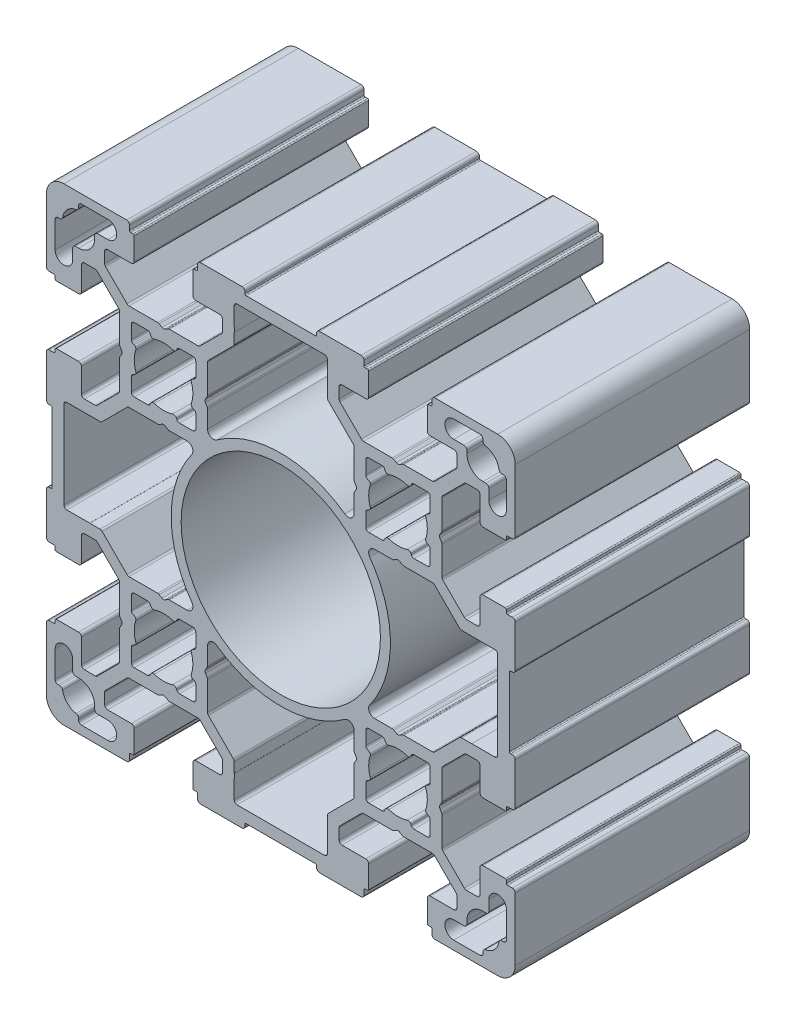
from build123d import *

# Parameters (mm, degrees)
SKETCH_1_R      = 17
EXTRUDE_2_DEPTH = 40


with BuildPart() as part:
    # Эскиз1 → Бобышка-Вытянуть2 (new body)
    with BuildSketch(Plane.XY):
        with BuildLine():
            Line((19.10095497, 46.510086301), (19.60095497, 46.798761436))
            ThreePointArc((19.60095497, 46.798761436), (19.721545448, 46.848711647), (19.85095497, 46.865748734))
            Line((19.85095497, 46.865748734), (24.729634627, 46.865748734))
            ThreePointArc((24.729634627, 46.865748734), (24.920976343, 46.903808968), (25.083188017, 47.012195343))
            Line((25.083188017, 47.012195343), (28.754508361, 50.683515687))
            ThreePointArc((28.754508361, 50.683515687), (28.862894737, 50.845727361), (28.90095497, 51.037069077))
            Line((28.90095497, 51.037069077), (28.90095497, 52.865748734))
            ThreePointArc((28.90095497, 52.865748734), (28.754508361, 53.219302125), (28.40095497, 53.365748734))
            Line((28.40095497, 53.365748734), (24.35095497, 53.365748734))
            ThreePointArc((24.35095497, 53.365748734), (23.99740158, 53.512195343), (23.85095497, 53.865748734))
            Line((23.85095497, 53.865748734), (23.85095497, 57.665748734))
            ThreePointArc((23.85095497, 57.665748734), (23.909533614, 57.80717009), (24.05095497, 57.865748734))
            Line((24.05095497, 57.865748734), (24.45095497, 57.865748734))
            ThreePointArc((24.45095497, 57.865748734), (24.592376327, 57.924327378), (24.65095497, 58.065748734))
            Line((24.65095497, 58.065748734), (24.65095497, 58.865748734))
            ThreePointArc((24.65095497, 58.865748734), (24.79740158, 59.219302125), (25.15095497, 59.365748734))
            Line((25.15095497, 59.365748734), (32.24095497, 59.365748734))
            ThreePointArc((32.24095497, 59.365748734), (32.594508361, 59.219302125), (32.74095497, 58.865748734))
            Line((32.74095497, 58.865748734), (32.74095497, 58.565748734))
            ThreePointArc((32.74095497, 58.565748734), (32.799533614, 58.424327378), (32.94095497, 58.365748734))
            Line((32.94095497, 58.365748734), (44.76095497, 58.365748734))
            ThreePointArc((44.76095497, 58.365748734), (44.902376327, 58.424327378), (44.96095497, 58.565748734))
            Line((44.96095497, 58.565748734), (44.96095497, 58.865748734))
            ThreePointArc((44.96095497, 58.865748734), (45.10740158, 59.219302125), (45.46095497, 59.365748734))
            Line((45.46095497, 59.365748734), (52.55095497, 59.365748734))
            ThreePointArc((52.55095497, 59.365748734), (52.904508361, 59.219302125), (53.05095497, 58.865748734))
            Line((53.05095497, 58.865748734), (53.05095497, 58.065748734))
            ThreePointArc((53.05095497, 58.065748734), (53.109533614, 57.924327378), (53.25095497, 57.865748734))
            Line((53.25095497, 57.865748734), (53.65095497, 57.865748734))
            ThreePointArc((53.65095497, 57.865748734), (53.792376327, 57.80717009), (53.85095497, 57.665748734))
            Line((53.85095497, 57.665748734), (53.85095497, 53.865748734))
            ThreePointArc((53.85095497, 53.865748734), (53.704508361, 53.512195343), (53.35095497, 53.365748734))
            Line((53.35095497, 53.365748734), (49.30095497, 53.365748734))
            ThreePointArc((49.30095497, 53.365748734), (48.94740158, 53.219302125), (48.80095497, 52.865748734))
            Line((48.80095497, 52.865748734), (48.80095497, 51.037069077))
            ThreePointArc((48.80095497, 51.037069077), (48.839015204, 50.845727361), (48.94740158, 50.683515687))
            Line((48.94740158, 50.683515687), (52.618721923, 47.012195343))
            ThreePointArc((52.618721923, 47.012195343), (52.780933598, 46.903808968), (52.972275314, 46.865748734))
            Line((52.972275314, 46.865748734), (57.85095497, 46.865748734))
            ThreePointArc((57.85095497, 46.865748734), (57.980364493, 46.848711647), (58.10095497, 46.798761436))
            Line((58.10095497, 46.798761436), (58.60095497, 46.510086301))
            ThreePointArc((58.60095497, 46.510086301), (58.85095497, 46.443099003), (59.10095497, 46.510086301))
            Line((59.10095497, 46.510086301), (59.60095497, 46.798761436))
            ThreePointArc((59.60095497, 46.798761436), (59.721545448, 46.848711647), (59.85095497, 46.865748734))
            Line((59.85095497, 46.865748734), (64.729634627, 46.865748734))
            ThreePointArc((64.729634627, 46.865748734), (64.920976343, 46.903808968), (65.083188017, 47.012195343))
            Line((65.083188017, 47.012195343), (68.754508361, 50.683515687))
            ThreePointArc((68.754508361, 50.683515687), (68.862894737, 50.845727361), (68.90095497, 51.037069077))
            Line((68.90095497, 51.037069077), (68.90095497, 52.865748734))
            ThreePointArc((68.90095497, 52.865748734), (68.754508361, 53.219302125), (68.40095497, 53.365748734))
            Line((68.40095497, 53.365748734), (64.35095497, 53.365748734))
            ThreePointArc((64.35095497, 53.365748734), (63.99740158, 53.512195343), (63.85095497, 53.865748734))
            Line((63.85095497, 53.865748734), (63.85095497, 57.665748734))
            ThreePointArc((63.85095497, 57.665748734), (63.909533614, 57.80717009), (64.05095497, 57.865748734))
            Line((64.05095497, 57.865748734), (64.45095497, 57.865748734))
            ThreePointArc((64.45095497, 57.865748734), (64.592376327, 57.924327378), (64.65095497, 58.065748734))
            Line((64.65095497, 58.065748734), (64.65095497, 58.865748734))
            ThreePointArc((64.65095497, 58.865748734), (64.79740158, 59.219302125), (65.15095497, 59.365748734))
            Line((65.15095497, 59.365748734), (75.85095497, 59.365748734))
            ThreePointArc((75.85095497, 59.365748734), (77.972275314, 58.487069077), (78.85095497, 56.365748734))
            Line((78.85095497, 56.365748734), (78.85095497, 45.665748734))
            ThreePointArc((78.85095497, 45.665748734), (78.704508361, 45.312195343), (78.35095497, 45.165748734))
            Line((78.35095497, 45.165748734), (77.55095497, 45.165748734))
            ThreePointArc((77.55095497, 45.165748734), (77.409533614, 45.10717009), (77.35095497, 44.965748734))
            Line((77.35095497, 44.965748734), (77.35095497, 44.565748734))
            ThreePointArc((77.35095497, 44.565748734), (77.292376327, 44.424327378), (77.15095497, 44.365748734))
            Line((77.15095497, 44.365748734), (73.35095497, 44.365748734))
            ThreePointArc((73.35095497, 44.365748734), (72.99740158, 44.512195343), (72.85095497, 44.865748734))
            Line((72.85095497, 44.865748734), (72.85095497, 48.915748734))
            ThreePointArc((72.85095497, 48.915748734), (72.704508361, 49.269302125), (72.35095497, 49.415748734))
            Line((72.35095497, 49.415748734), (70.522275314, 49.415748734))
            ThreePointArc((70.522275314, 49.415748734), (70.330933598, 49.3776885), (70.168721923, 49.269302125))
            Line((70.168721923, 49.269302125), (66.49740158, 45.597981781))
            ThreePointArc((66.49740158, 45.597981781), (66.389015204, 45.435770107), (66.35095497, 45.24442839))
            Line((66.35095497, 45.24442839), (66.35095497, 40.365748734))
            ThreePointArc((66.35095497, 40.365748734), (66.333917884, 40.236339211), (66.283967672, 40.115748734))
            Line((66.283967672, 40.115748734), (65.995292538, 39.615748734))
            ThreePointArc((65.995292538, 39.615748734), (65.92830524, 39.365748734), (65.995292538, 39.115748734))
            Line((65.995292538, 39.115748734), (66.283967672, 38.615748734))
            ThreePointArc((66.283967672, 38.615748734), (66.333917884, 38.495158256), (66.35095497, 38.365748734))
            Line((66.35095497, 38.365748734), (66.35095497, 33.487069077))
            ThreePointArc((66.35095497, 33.487069077), (66.389015204, 33.295727361), (66.49740158, 33.133515687))
            Line((66.49740158, 33.133515687), (70.168721923, 29.462195343))
            ThreePointArc((70.168721923, 29.462195343), (70.330933598, 29.353808968), (70.522275314, 29.315748734))
            Line((70.522275314, 29.315748734), (72.35095497, 29.315748734))
            ThreePointArc((72.35095497, 29.315748734), (72.704508361, 29.462195343), (72.85095497, 29.815748734))
            Line((72.85095497, 29.815748734), (72.85095497, 33.865748734))
            ThreePointArc((72.85095497, 33.865748734), (72.99740158, 34.219302125), (73.35095497, 34.365748734))
            Line((73.35095497, 34.365748734), (77.15095497, 34.365748734))
            ThreePointArc((77.15095497, 34.365748734), (77.292376327, 34.30717009), (77.35095497, 34.165748734))
            Line((77.35095497, 34.165748734), (77.35095497, 33.765748734))
            ThreePointArc((77.35095497, 33.765748734), (77.409533614, 33.624327378), (77.55095497, 33.565748734))
            Line((77.55095497, 33.565748734), (78.35095497, 33.565748734))
            ThreePointArc((78.35095497, 33.565748734), (78.704508361, 33.419302125), (78.85095497, 33.065748734))
            Line((78.85095497, 33.065748734), (78.85095497, 25.975748734))
            ThreePointArc((78.85095497, 25.975748734), (78.704508361, 25.622195343), (78.35095497, 25.475748734))
            Line((78.35095497, 25.475748734), (78.05095497, 25.475748734))
            ThreePointArc((78.05095497, 25.475748734), (77.909533614, 25.41717009), (77.85095497, 25.275748734))
            Line((77.85095497, 25.275748734), (77.85095497, 13.455748734))
            ThreePointArc((77.85095497, 13.455748734), (77.909533614, 13.314327378), (78.05095497, 13.255748734))
            Line((78.05095497, 13.255748734), (78.35095497, 13.255748734))
            ThreePointArc((78.35095497, 13.255748734), (78.704508361, 13.109302125), (78.85095497, 12.755748734))
            Line((78.85095497, 12.755748734), (78.85095497, 5.665748734))
            ThreePointArc((78.85095497, 5.665748734), (78.704508361, 5.312195343), (78.35095497, 5.165748734))
            Line((78.35095497, 5.165748734), (77.55095497, 5.165748734))
            ThreePointArc((77.55095497, 5.165748734), (77.409533614, 5.10717009), (77.35095497, 4.965748734))
            Line((77.35095497, 4.965748734), (77.35095497, 4.565748734))
            ThreePointArc((77.35095497, 4.565748734), (77.292376327, 4.424327378), (77.15095497, 4.365748734))
            Line((77.15095497, 4.365748734), (73.35095497, 4.365748734))
            ThreePointArc((73.35095497, 4.365748734), (72.99740158, 4.512195343), (72.85095497, 4.865748734))
            Line((72.85095497, 4.865748734), (72.85095497, 8.915748734))
            ThreePointArc((72.85095497, 8.915748734), (72.704508361, 9.269302125), (72.35095497, 9.415748734))
            Line((72.35095497, 9.415748734), (70.522275314, 9.415748734))
            ThreePointArc((70.522275314, 9.415748734), (70.330933598, 9.3776885), (70.168721923, 9.269302125))
            Line((70.168721923, 9.269302125), (66.49740158, 5.597981781))
            ThreePointArc((66.49740158, 5.597981781), (66.389015204, 5.435770107), (66.35095497, 5.24442839))
            Line((66.35095497, 5.24442839), (66.35095497, 0.365748734))
            ThreePointArc((66.35095497, 0.365748734), (66.333917884, 0.236339211), (66.283967672, 0.115748734))
            Line((66.283967672, 0.115748734), (65.995292538, -0.384251266))
            ThreePointArc((65.995292538, -0.384251266), (65.92830524, -0.634251266), (65.995292538, -0.884251266))
            Line((65.995292538, -0.884251266), (66.283967672, -1.384251266))
            ThreePointArc((66.283967672, -1.384251266), (66.333917884, -1.504841744), (66.35095497, -1.634251266))
            Line((66.35095497, -1.634251266), (66.35095497, -6.512930923))
            ThreePointArc((66.35095497, -6.512930923), (66.389015204, -6.704272639), (66.49740158, -6.866484313))
            Line((66.49740158, -6.866484313), (70.168721923, -10.537804657))
            ThreePointArc((70.168721923, -10.537804657), (70.330933598, -10.646191032), (70.522275314, -10.684251266))
            Line((70.522275314, -10.684251266), (72.35095497, -10.684251266))
            ThreePointArc((72.35095497, -10.684251266), (72.704508361, -10.537804657), (72.85095497, -10.184251266))
            Line((72.85095497, -10.184251266), (72.85095497, -6.134251266))
            ThreePointArc((72.85095497, -6.134251266), (72.99740158, -5.780697875), (73.35095497, -5.634251266))
            Line((73.35095497, -5.634251266), (77.15095497, -5.634251266))
            ThreePointArc((77.15095497, -5.634251266), (77.292376327, -5.69282991), (77.35095497, -5.834251266))
            Line((77.35095497, -5.834251266), (77.35095497, -6.234251266))
            ThreePointArc((77.35095497, -6.234251266), (77.409533614, -6.375672622), (77.55095497, -6.434251266))
            Line((77.55095497, -6.434251266), (78.35095497, -6.434251266))
            ThreePointArc((78.35095497, -6.434251266), (78.704508361, -6.580697875), (78.85095497, -6.934251266))
            Line((78.85095497, -6.934251266), (78.85095497, -17.634251266))
            ThreePointArc((78.85095497, -17.634251266), (77.972275314, -19.75557161), (75.85095497, -20.634251266))
            Line((75.85095497, -20.634251266), (65.15095497, -20.634251266))
            ThreePointArc((65.15095497, -20.634251266), (64.79740158, -20.487804657), (64.65095497, -20.134251266))
            Line((64.65095497, -20.134251266), (64.65095497, -19.334251266))
            ThreePointArc((64.65095497, -19.334251266), (64.592376327, -19.19282991), (64.45095497, -19.134251266))
            Line((64.45095497, -19.134251266), (64.05095497, -19.134251266))
            ThreePointArc((64.05095497, -19.134251266), (63.909533614, -19.075672622), (63.85095497, -18.934251266))
            Line((63.85095497, -18.934251266), (63.85095497, -15.134251266))
            ThreePointArc((63.85095497, -15.134251266), (63.99740158, -14.780697875), (64.35095497, -14.634251266))
            Line((64.35095497, -14.634251266), (68.40095497, -14.634251266))
            ThreePointArc((68.40095497, -14.634251266), (68.754508361, -14.487804657), (68.90095497, -14.134251266))
            Line((68.90095497, -14.134251266), (68.90095497, -12.30557161))
            ThreePointArc((68.90095497, -12.30557161), (68.862894737, -12.114229893), (68.754508361, -11.952018219))
            Line((68.754508361, -11.952018219), (65.083188017, -8.280697875))
            ThreePointArc((65.083188017, -8.280697875), (64.920976343, -8.1723115), (64.729634627, -8.134251266))
            Line((64.729634627, -8.134251266), (59.85095497, -8.134251266))
            ThreePointArc((59.85095497, -8.134251266), (59.721545448, -8.117214179), (59.60095497, -8.067263968))
            Line((59.60095497, -8.067263968), (59.10095497, -7.778588833))
            ThreePointArc((59.10095497, -7.778588833), (58.85095497, -7.711601535), (58.60095497, -7.778588833))
            Line((58.60095497, -7.778588833), (58.10095497, -8.067263968))
            ThreePointArc((58.10095497, -8.067263968), (57.980364493, -8.117214179), (57.85095497, -8.134251266))
            Line((57.85095497, -8.134251266), (52.972275314, -8.134251266))
            ThreePointArc((52.972275314, -8.134251266), (52.780933598, -8.1723115), (52.618721923, -8.280697875))
            Line((52.618721923, -8.280697875), (48.94740158, -11.952018219))
            ThreePointArc((48.94740158, -11.952018219), (48.839015204, -12.114229893), (48.80095497, -12.30557161))
            Line((48.80095497, -12.30557161), (48.80095497, -14.134251266))
            ThreePointArc((48.80095497, -14.134251266), (48.94740158, -14.487804657), (49.30095497, -14.634251266))
            Line((49.30095497, -14.634251266), (53.35095497, -14.634251266))
            ThreePointArc((53.35095497, -14.634251266), (53.704508361, -14.780697875), (53.85095497, -15.134251266))
            Line((53.85095497, -15.134251266), (53.85095497, -18.934251266))
            ThreePointArc((53.85095497, -18.934251266), (53.792376327, -19.075672622), (53.65095497, -19.134251266))
            Line((53.65095497, -19.134251266), (53.25095497, -19.134251266))
            ThreePointArc((53.25095497, -19.134251266), (53.109533614, -19.19282991), (53.05095497, -19.334251266))
            Line((53.05095497, -19.334251266), (53.05095497, -20.134251266))
            ThreePointArc((53.05095497, -20.134251266), (52.904508361, -20.487804657), (52.55095497, -20.634251266))
            Line((52.55095497, -20.634251266), (45.46095497, -20.634251266))
            ThreePointArc((45.46095497, -20.634251266), (45.10740158, -20.487804657), (44.96095497, -20.134251266))
            Line((44.96095497, -20.134251266), (44.96095497, -19.834251266))
            ThreePointArc((44.96095497, -19.834251266), (44.902376327, -19.69282991), (44.76095497, -19.634251266))
            Line((44.76095497, -19.634251266), (32.94095497, -19.634251266))
            ThreePointArc((32.94095497, -19.634251266), (32.799533614, -19.69282991), (32.74095497, -19.834251266))
            Line((32.74095497, -19.834251266), (32.74095497, -20.134251266))
            ThreePointArc((32.74095497, -20.134251266), (32.594508361, -20.487804657), (32.24095497, -20.634251266))
            Line((32.24095497, -20.634251266), (25.15095497, -20.634251266))
            ThreePointArc((25.15095497, -20.634251266), (24.79740158, -20.487804657), (24.65095497, -20.134251266))
            Line((24.65095497, -20.134251266), (24.65095497, -19.334251266))
            ThreePointArc((24.65095497, -19.334251266), (24.592376327, -19.19282991), (24.45095497, -19.134251266))
            Line((24.45095497, -19.134251266), (24.05095497, -19.134251266))
            ThreePointArc((24.05095497, -19.134251266), (23.909533614, -19.075672622), (23.85095497, -18.934251266))
            Line((23.85095497, -18.934251266), (23.85095497, -15.134251266))
            ThreePointArc((23.85095497, -15.134251266), (23.99740158, -14.780697875), (24.35095497, -14.634251266))
            Line((24.35095497, -14.634251266), (28.40095497, -14.634251266))
            ThreePointArc((28.40095497, -14.634251266), (28.754508361, -14.487804657), (28.90095497, -14.134251266))
            Line((28.90095497, -14.134251266), (28.90095497, -12.30557161))
            ThreePointArc((28.90095497, -12.30557161), (28.862894737, -12.114229893), (28.754508361, -11.952018219))
            Line((28.754508361, -11.952018219), (25.083188017, -8.280697875))
            ThreePointArc((25.083188017, -8.280697875), (24.920976343, -8.1723115), (24.729634627, -8.134251266))
            Line((24.729634627, -8.134251266), (19.85095497, -8.134251266))
            ThreePointArc((19.85095497, -8.134251266), (19.721545448, -8.117214179), (19.60095497, -8.067263968))
            Line((19.60095497, -8.067263968), (19.10095497, -7.778588833))
            ThreePointArc((19.10095497, -7.778588833), (18.85095497, -7.711601535), (18.60095497, -7.778588833))
            Line((18.60095497, -7.778588833), (18.10095497, -8.067263968))
            ThreePointArc((18.10095497, -8.067263968), (17.980364493, -8.117214179), (17.85095497, -8.134251266))
            Line((17.85095497, -8.134251266), (12.972275314, -8.134251266))
            ThreePointArc((12.972275314, -8.134251266), (12.780933598, -8.1723115), (12.618721923, -8.280697875))
            Line((12.618721923, -8.280697875), (8.94740158, -11.952018219))
            ThreePointArc((8.94740158, -11.952018219), (8.839015204, -12.114229893), (8.80095497, -12.30557161))
            Line((8.80095497, -12.30557161), (8.80095497, -14.134251266))
            ThreePointArc((8.80095497, -14.134251266), (8.94740158, -14.487804657), (9.30095497, -14.634251266))
            Line((9.30095497, -14.634251266), (13.35095497, -14.634251266))
            ThreePointArc((13.35095497, -14.634251266), (13.704508361, -14.780697875), (13.85095497, -15.134251266))
            Line((13.85095497, -15.134251266), (13.85095497, -18.934251266))
            ThreePointArc((13.85095497, -18.934251266), (13.792376327, -19.075672622), (13.65095497, -19.134251266))
            Line((13.65095497, -19.134251266), (13.25095497, -19.134251266))
            ThreePointArc((13.25095497, -19.134251266), (13.109533614, -19.19282991), (13.05095497, -19.334251266))
            Line((13.05095497, -19.334251266), (13.05095497, -20.134251266))
            ThreePointArc((13.05095497, -20.134251266), (12.904508361, -20.487804657), (12.55095497, -20.634251266))
            Line((12.55095497, -20.634251266), (1.85095497, -20.634251266))
            ThreePointArc((1.85095497, -20.634251266), (-0.270365373, -19.75557161), (-1.14904503, -17.634251266))
            Line((-1.14904503, -17.634251266), (-1.14904503, -6.934251266))
            ThreePointArc((-1.14904503, -6.934251266), (-1.00259842, -6.580697875), (-0.64904503, -6.434251266))
            Line((-0.64904503, -6.434251266), (0.15095497, -6.434251266))
            ThreePointArc((0.15095497, -6.434251266), (0.292376327, -6.375672622), (0.35095497, -6.234251266))
            Line((0.35095497, -6.234251266), (0.35095497, -5.834251266))
            ThreePointArc((0.35095497, -5.834251266), (0.409533614, -5.69282991), (0.55095497, -5.634251266))
            Line((0.55095497, -5.634251266), (4.35095497, -5.634251266))
            ThreePointArc((4.35095497, -5.634251266), (4.704508361, -5.780697875), (4.85095497, -6.134251266))
            Line((4.85095497, -6.134251266), (4.85095497, -10.184251266))
            ThreePointArc((4.85095497, -10.184251266), (4.99740158, -10.537804657), (5.35095497, -10.684251266))
            Line((5.35095497, -10.684251266), (7.179634627, -10.684251266))
            ThreePointArc((7.179634627, -10.684251266), (7.370976343, -10.646191032), (7.533188017, -10.537804657))
            Line((7.533188017, -10.537804657), (11.204508361, -6.866484313))
            ThreePointArc((11.204508361, -6.866484313), (11.312894737, -6.704272639), (11.35095497, -6.512930923))
            Line((11.35095497, -6.512930923), (11.35095497, -1.634251266))
            ThreePointArc((11.35095497, -1.634251266), (11.367992057, -1.504841744), (11.417942269, -1.384251266))
            Line((11.417942269, -1.384251266), (11.706617403, -0.884251266))
            ThreePointArc((11.706617403, -0.884251266), (11.773604701, -0.634251266), (11.706617403, -0.384251266))
            Line((11.706617403, -0.384251266), (11.417942269, 0.115748734))
            ThreePointArc((11.417942269, 0.115748734), (11.367992057, 0.236339211), (11.35095497, 0.365748734))
            Line((11.35095497, 0.365748734), (11.35095497, 5.24442839))
            ThreePointArc((11.35095497, 5.24442839), (11.312894737, 5.435770107), (11.204508361, 5.597981781))
            Line((11.204508361, 5.597981781), (7.533188017, 9.269302125))
            ThreePointArc((7.533188017, 9.269302125), (7.370976343, 9.3776885), (7.179634627, 9.415748734))
            Line((7.179634627, 9.415748734), (5.35095497, 9.415748734))
            ThreePointArc((5.35095497, 9.415748734), (4.99740158, 9.269302125), (4.85095497, 8.915748734))
            Line((4.85095497, 8.915748734), (4.85095497, 4.865748734))
            ThreePointArc((4.85095497, 4.865748734), (4.704508361, 4.512195343), (4.35095497, 4.365748734))
            Line((4.35095497, 4.365748734), (0.55095497, 4.365748734))
            ThreePointArc((0.55095497, 4.365748734), (0.409533614, 4.424327378), (0.35095497, 4.565748734))
            Line((0.35095497, 4.565748734), (0.35095497, 4.965748734))
            ThreePointArc((0.35095497, 4.965748734), (0.292376327, 5.10717009), (0.15095497, 5.165748734))
            Line((0.15095497, 5.165748734), (-0.64904503, 5.165748734))
            ThreePointArc((-0.64904503, 5.165748734), (-1.00259842, 5.312195343), (-1.14904503, 5.665748734))
            Line((-1.14904503, 5.665748734), (-1.14904503, 12.755748734))
            ThreePointArc((-1.14904503, 12.755748734), (-1.00259842, 13.109302125), (-0.64904503, 13.255748734))
            Line((-0.64904503, 13.255748734), (-0.34904503, 13.255748734))
            ThreePointArc((-0.34904503, 13.255748734), (-0.207623673, 13.314327378), (-0.14904503, 13.455748734))
            Line((-0.14904503, 13.455748734), (-0.14904503, 25.275748734))
            ThreePointArc((-0.14904503, 25.275748734), (-0.207623673, 25.41717009), (-0.34904503, 25.475748734))
            Line((-0.34904503, 25.475748734), (-0.64904503, 25.475748734))
            ThreePointArc((-0.64904503, 25.475748734), (-1.00259842, 25.622195343), (-1.14904503, 25.975748734))
            Line((-1.14904503, 25.975748734), (-1.14904503, 33.065748734))
            ThreePointArc((-1.14904503, 33.065748734), (-1.00259842, 33.419302125), (-0.64904503, 33.565748734))
            Line((-0.64904503, 33.565748734), (0.15095497, 33.565748734))
            ThreePointArc((0.15095497, 33.565748734), (0.292376327, 33.624327378), (0.35095497, 33.765748734))
            Line((0.35095497, 33.765748734), (0.35095497, 34.165748734))
            ThreePointArc((0.35095497, 34.165748734), (0.409533614, 34.30717009), (0.55095497, 34.365748734))
            Line((0.55095497, 34.365748734), (4.35095497, 34.365748734))
            ThreePointArc((4.35095497, 34.365748734), (4.704508361, 34.219302125), (4.85095497, 33.865748734))
            Line((4.85095497, 33.865748734), (4.85095497, 29.815748734))
            ThreePointArc((4.85095497, 29.815748734), (4.99740158, 29.462195343), (5.35095497, 29.315748734))
            Line((5.35095497, 29.315748734), (7.179634627, 29.315748734))
            ThreePointArc((7.179634627, 29.315748734), (7.370976343, 29.353808968), (7.533188017, 29.462195343))
            Line((7.533188017, 29.462195343), (11.204508361, 33.133515687))
            ThreePointArc((11.204508361, 33.133515687), (11.312894737, 33.295727361), (11.35095497, 33.487069077))
            Line((11.35095497, 33.487069077), (11.35095497, 38.365748734))
            ThreePointArc((11.35095497, 38.365748734), (11.367992057, 38.495158256), (11.417942269, 38.615748734))
            Line((11.417942269, 38.615748734), (11.706617403, 39.115748734))
            ThreePointArc((11.706617403, 39.115748734), (11.773604701, 39.365748734), (11.706617403, 39.615748734))
            Line((11.706617403, 39.615748734), (11.417942269, 40.115748734))
            ThreePointArc((11.417942269, 40.115748734), (11.367992057, 40.236339211), (11.35095497, 40.365748734))
            Line((11.35095497, 40.365748734), (11.35095497, 45.24442839))
            ThreePointArc((11.35095497, 45.24442839), (11.312894737, 45.435770107), (11.204508361, 45.597981781))
            Line((11.204508361, 45.597981781), (7.533188017, 49.269302125))
            ThreePointArc((7.533188017, 49.269302125), (7.370976343, 49.3776885), (7.179634627, 49.415748734))
            Line((7.179634627, 49.415748734), (5.35095497, 49.415748734))
            ThreePointArc((5.35095497, 49.415748734), (4.99740158, 49.269302125), (4.85095497, 48.915748734))
            Line((4.85095497, 48.915748734), (4.85095497, 44.865748734))
            ThreePointArc((4.85095497, 44.865748734), (4.704508361, 44.512195343), (4.35095497, 44.365748734))
            Line((4.35095497, 44.365748734), (0.55095497, 44.365748734))
            ThreePointArc((0.55095497, 44.365748734), (0.409533614, 44.424327378), (0.35095497, 44.565748734))
            Line((0.35095497, 44.565748734), (0.35095497, 44.965748734))
            ThreePointArc((0.35095497, 44.965748734), (0.292376327, 45.10717009), (0.15095497, 45.165748734))
            Line((0.15095497, 45.165748734), (-0.64904503, 45.165748734))
            ThreePointArc((-0.64904503, 45.165748734), (-1.00259842, 45.312195343), (-1.14904503, 45.665748734))
            Line((-1.14904503, 45.665748734), (-1.14904503, 56.365748734))
            ThreePointArc((-1.14904503, 56.365748734), (-0.270365373, 58.487069077), (1.85095497, 59.365748734))
            Line((1.85095497, 59.365748734), (12.55095497, 59.365748734))
            ThreePointArc((12.55095497, 59.365748734), (12.904508361, 59.219302125), (13.05095497, 58.865748734))
            Line((13.05095497, 58.865748734), (13.05095497, 58.065748734))
            ThreePointArc((13.05095497, 58.065748734), (13.109533614, 57.924327378), (13.25095497, 57.865748734))
            Line((13.25095497, 57.865748734), (13.65095497, 57.865748734))
            ThreePointArc((13.65095497, 57.865748734), (13.792376327, 57.80717009), (13.85095497, 57.665748734))
            Line((13.85095497, 57.665748734), (13.85095497, 53.865748734))
            ThreePointArc((13.85095497, 53.865748734), (13.704508361, 53.512195343), (13.35095497, 53.365748734))
            Line((13.35095497, 53.365748734), (9.30095497, 53.365748734))
            ThreePointArc((9.30095497, 53.365748734), (8.94740158, 53.219302125), (8.80095497, 52.865748734))
            Line((8.80095497, 52.865748734), (8.80095497, 51.037069077))
            ThreePointArc((8.80095497, 51.037069077), (8.839015204, 50.845727361), (8.94740158, 50.683515687))
            Line((8.94740158, 50.683515687), (12.618721923, 47.012195343))
            ThreePointArc((12.618721923, 47.012195343), (12.780933598, 46.903808968), (12.972275314, 46.865748734))
            Line((12.972275314, 46.865748734), (17.85095497, 46.865748734))
            ThreePointArc((17.85095497, 46.865748734), (17.980364493, 46.848711647), (18.10095497, 46.798761436))
            Line((18.10095497, 46.798761436), (18.60095497, 46.510086301))
            ThreePointArc((18.60095497, 46.510086301), (18.85095497, 46.443099003), (19.10095497, 46.510086301))
        make_face()
        with Locations((38.85095497, 19.365748734)):
            Circle(SKETCH_1_R, mode=Mode.SUBTRACT)
        with BuildLine():
            Line((4.35095497, 57.365748734), (4.35095497, 57.077056879))
            ThreePointArc((4.35095497, 57.077056879), (4.230732233, 56.751835061), (3.927878047, 56.583009472))
            ThreePointArc((3.927878047, 56.583009472), (2.406411322, 55.810292382), (1.633694233, 54.288825657))
            ThreePointArc((1.633694233, 54.288825657), (1.464868644, 53.985971471), (1.139646826, 53.865748734))
            Line((1.139646826, 53.865748734), (0.85095497, 53.865748734))
            ThreePointArc((0.85095497, 53.865748734), (0.49740158, 53.719302125), (0.35095497, 53.365748734))
            Line((0.35095497, 53.365748734), (0.35095497, 48.865748734))
            ThreePointArc((0.35095497, 48.865748734), (1.85095497, 47.365748734), (3.35095497, 48.865748734))
            Line((3.35095497, 48.865748734), (3.35095497, 50.615748734))
            ThreePointArc((3.35095497, 50.615748734), (3.49740158, 50.969302125), (3.85095497, 51.115748734))
            Line((3.85095497, 51.115748734), (4.35095497, 51.115748734))
            ThreePointArc((4.35095497, 51.115748734), (6.295498619, 51.921205086), (7.10095497, 53.865748734))
            Line((7.10095497, 53.865748734), (7.10095497, 54.365748734))
            ThreePointArc((7.10095497, 54.365748734), (7.24740158, 54.719302125), (7.60095497, 54.865748734))
            Line((7.60095497, 54.865748734), (9.35095497, 54.865748734))
            ThreePointArc((9.35095497, 54.865748734), (10.85095497, 56.365748734), (9.35095497, 57.865748734))
            Line((9.35095497, 57.865748734), (4.85095497, 57.865748734))
            ThreePointArc((4.85095497, 57.865748734), (4.49740158, 57.719302125), (4.35095497, 57.365748734))
        make_face(mode=Mode.SUBTRACT)
        with BuildLine():
            Line((19.85095497, 31.865748734), (22.855955752, 31.865748734))
            ThreePointArc((22.855955752, 31.865748734), (23.745831121, 31.321952447), (23.667884646, 30.281992389))
            ThreePointArc((23.667884646, 30.281992389), (20.15095497, 19.365748734), (23.667884646, 8.449505079))
            ThreePointArc((23.667884646, 8.449505079), (23.745831121, 7.409545021), (22.855955752, 6.865748734))
            Line((22.855955752, 6.865748734), (19.85095497, 6.865748734))
            ThreePointArc((19.85095497, 6.865748734), (19.721545448, 6.848711647), (19.60095497, 6.798761436))
            Line((19.60095497, 6.798761436), (19.10095497, 6.510086301))
            ThreePointArc((19.10095497, 6.510086301), (18.85095497, 6.443099003), (18.60095497, 6.510086301))
            Line((18.60095497, 6.510086301), (18.10095497, 6.798761436))
            ThreePointArc((18.10095497, 6.798761436), (17.980364493, 6.848711647), (17.85095497, 6.865748734))
            Line((17.85095497, 6.865748734), (12.972275314, 6.865748734))
            ThreePointArc((12.972275314, 6.865748734), (12.780933598, 6.903808968), (12.618721923, 7.012195343))
            Line((12.618721923, 7.012195343), (8.94740158, 10.683515687))
            Line((8.94740158, 10.683515687), (8.361615142, 11.269302125))
            ThreePointArc((8.361615142, 11.269302125), (8.199403468, 11.3776885), (8.008061752, 11.415748734))
            Line((8.008061752, 11.415748734), (6.265294799, 11.415748734))
            Line((6.265294799, 11.415748734), (6.270825406, 11.430739114))
            Line((6.270825406, 11.430739114), (2.352650755, 11.417450279))
            ThreePointArc((2.352650755, 11.417450279), (1.998001639, 11.56329497), (1.85095497, 11.917447404))
            Line((1.85095497, 11.917447404), (1.85095497, 26.814050064))
            ThreePointArc((1.85095497, 26.814050064), (1.998001639, 27.168202498), (2.352650755, 27.314047188))
            Line((2.352650755, 27.314047188), (6.270825406, 27.300758354))
            Line((6.270825406, 27.300758354), (6.265294799, 27.315748734))
            Line((6.265294799, 27.315748734), (8.008061752, 27.315748734))
            ThreePointArc((8.008061752, 27.315748734), (8.199403468, 27.353808968), (8.361615142, 27.462195343))
            Line((8.361615142, 27.462195343), (8.94740158, 28.047981781))
            Line((8.94740158, 28.047981781), (12.618721923, 31.719302125))
            ThreePointArc((12.618721923, 31.719302125), (12.780933598, 31.8276885), (12.972275314, 31.865748734))
            Line((12.972275314, 31.865748734), (17.85095497, 31.865748734))
            ThreePointArc((17.85095497, 31.865748734), (17.980364493, 31.882785821), (18.10095497, 31.932736032))
            Line((18.10095497, 31.932736032), (18.60095497, 32.221411167))
            ThreePointArc((18.60095497, 32.221411167), (18.85095497, 32.288398465), (19.10095497, 32.221411167))
            Line((19.10095497, 32.221411167), (19.60095497, 31.932736032))
            ThreePointArc((19.60095497, 31.932736032), (19.721545448, 31.882785821), (19.85095497, 31.865748734))
        make_face(mode=Mode.SUBTRACT)
        with BuildLine():
            Line((26.35095497, 38.365748734), (26.35095497, 35.360747952))
            ThreePointArc((26.35095497, 35.360747952), (26.894751258, 34.470872583), (27.934711316, 34.548819058))
            ThreePointArc((27.934711316, 34.548819058), (38.85095497, 38.065748734), (49.767198625, 34.548819058))
            ThreePointArc((49.767198625, 34.548819058), (50.807158683, 34.470872583), (51.35095497, 35.360747952))
            Line((51.35095497, 35.360747952), (51.35095497, 38.365748734))
            ThreePointArc((51.35095497, 38.365748734), (51.367992057, 38.495158256), (51.417942269, 38.615748734))
            Line((51.417942269, 38.615748734), (51.706617403, 39.115748734))
            ThreePointArc((51.706617403, 39.115748734), (51.773604701, 39.365748734), (51.706617403, 39.615748734))
            Line((51.706617403, 39.615748734), (51.417942269, 40.115748734))
            ThreePointArc((51.417942269, 40.115748734), (51.367992057, 40.236339211), (51.35095497, 40.365748734))
            Line((51.35095497, 40.365748734), (51.35095497, 45.24442839))
            ThreePointArc((51.35095497, 45.24442839), (51.312894737, 45.435770107), (51.204508361, 45.597981781))
            Line((51.204508361, 45.597981781), (47.533188017, 49.269302125))
            Line((47.533188017, 49.269302125), (46.94740158, 49.855088562))
            ThreePointArc((46.94740158, 49.855088562), (46.839015204, 50.017300237), (46.80095497, 50.208641953))
            Line((46.80095497, 50.208641953), (46.80095497, 51.951408906))
            Line((46.80095497, 51.951408906), (46.78596459, 51.945878298))
            Line((46.78596459, 51.945878298), (46.799253425, 55.86405295))
            ThreePointArc((46.799253425, 55.86405295), (46.653408734, 56.218702065), (46.299256301, 56.365748734))
            Line((46.299256301, 56.365748734), (31.40265364, 56.365748734))
            ThreePointArc((31.40265364, 56.365748734), (31.048501207, 56.218702065), (30.902656516, 55.86405295))
            Line((30.902656516, 55.86405295), (30.915945351, 51.945878298))
            Line((30.915945351, 51.945878298), (30.90095497, 51.951408906))
            Line((30.90095497, 51.951408906), (30.90095497, 50.208641953))
            ThreePointArc((30.90095497, 50.208641953), (30.862894737, 50.017300237), (30.754508361, 49.855088562))
            Line((30.754508361, 49.855088562), (30.168721923, 49.269302125))
            Line((30.168721923, 49.269302125), (26.49740158, 45.597981781))
            ThreePointArc((26.49740158, 45.597981781), (26.389015204, 45.435770107), (26.35095497, 45.24442839))
            Line((26.35095497, 45.24442839), (26.35095497, 40.365748734))
            ThreePointArc((26.35095497, 40.365748734), (26.333917884, 40.236339211), (26.283967672, 40.115748734))
            Line((26.283967672, 40.115748734), (25.995292538, 39.615748734))
            ThreePointArc((25.995292538, 39.615748734), (25.92830524, 39.365748734), (25.995292538, 39.115748734))
            Line((25.995292538, 39.115748734), (26.283967672, 38.615748734))
            ThreePointArc((26.283967672, 38.615748734), (26.333917884, 38.495158256), (26.35095497, 38.365748734))
        make_face(mode=Mode.SUBTRACT)
        with BuildLine():
            Line((54.845954189, 31.865748734), (57.85095497, 31.865748734))
            ThreePointArc((57.85095497, 31.865748734), (57.980364493, 31.882785821), (58.10095497, 31.932736032))
            Line((58.10095497, 31.932736032), (58.60095497, 32.221411167))
            ThreePointArc((58.60095497, 32.221411167), (58.85095497, 32.288398465), (59.10095497, 32.221411167))
            Line((59.10095497, 32.221411167), (59.60095497, 31.932736032))
            ThreePointArc((59.60095497, 31.932736032), (59.721545448, 31.882785821), (59.85095497, 31.865748734))
            Line((59.85095497, 31.865748734), (64.729634627, 31.865748734))
            ThreePointArc((64.729634627, 31.865748734), (64.920976343, 31.8276885), (65.083188017, 31.719302125))
            Line((65.083188017, 31.719302125), (68.754508361, 28.047981781))
            Line((68.754508361, 28.047981781), (69.340294799, 27.462195343))
            ThreePointArc((69.340294799, 27.462195343), (69.502506473, 27.353808968), (69.693848189, 27.315748734))
            Line((69.693848189, 27.315748734), (71.436615142, 27.315748734))
            Line((71.436615142, 27.315748734), (71.431084535, 27.300758354))
            Line((71.431084535, 27.300758354), (75.349259186, 27.314047188))
            ThreePointArc((75.349259186, 27.314047188), (75.703908302, 27.168202498), (75.85095497, 26.814050064))
            Line((75.85095497, 26.814050064), (75.85095497, 11.917447404))
            ThreePointArc((75.85095497, 11.917447404), (75.703908302, 11.56329497), (75.349259186, 11.417450279))
            Line((75.349259186, 11.417450279), (71.431084535, 11.430739114))
            Line((71.431084535, 11.430739114), (71.436615142, 11.415748734))
            Line((71.436615142, 11.415748734), (69.693848189, 11.415748734))
            ThreePointArc((69.693848189, 11.415748734), (69.502506473, 11.3776885), (69.340294799, 11.269302125))
            Line((69.340294799, 11.269302125), (68.754508361, 10.683515687))
            Line((68.754508361, 10.683515687), (65.083188017, 7.012195343))
            ThreePointArc((65.083188017, 7.012195343), (64.920976343, 6.903808968), (64.729634627, 6.865748734))
            Line((64.729634627, 6.865748734), (59.85095497, 6.865748734))
            ThreePointArc((59.85095497, 6.865748734), (59.721545448, 6.848711647), (59.60095497, 6.798761436))
            Line((59.60095497, 6.798761436), (59.10095497, 6.510086301))
            ThreePointArc((59.10095497, 6.510086301), (58.85095497, 6.443099003), (58.60095497, 6.510086301))
            Line((58.60095497, 6.510086301), (58.10095497, 6.798761436))
            ThreePointArc((58.10095497, 6.798761436), (57.980364493, 6.848711647), (57.85095497, 6.865748734))
            Line((57.85095497, 6.865748734), (54.845954189, 6.865748734))
            ThreePointArc((54.845954189, 6.865748734), (53.95607882, 7.409545021), (54.034025295, 8.449505079))
            ThreePointArc((54.034025295, 8.449505079), (57.55095497, 19.365748734), (54.034025295, 30.281992389))
            ThreePointArc((54.034025295, 30.281992389), (53.95607882, 31.321952447), (54.845954189, 31.865748734))
        make_face(mode=Mode.SUBTRACT)
        with BuildLine():
            Line((13.651580436, 41.635033061), (13.830480159, 41.557245248))
            ThreePointArc((13.830480159, 41.557245248), (14.087640111, 41.302617792), (14.105637384, 40.941172804))
            ThreePointArc((14.105637384, 40.941172804), (13.85095497, 39.365748734), (14.105637384, 37.790324664))
            ThreePointArc((14.105637384, 37.790324664), (14.087640111, 37.428879675), (13.830480159, 37.17425222))
            Line((13.830480159, 37.17425222), (13.651580436, 37.096464407))
            ThreePointArc((13.651580436, 37.096464407), (13.432811893, 36.912080984), (13.35095497, 36.637934369))
            Line((13.35095497, 36.637934369), (13.35095497, 34.365748734))
            ThreePointArc((13.35095497, 34.365748734), (13.49740158, 34.012195343), (13.85095497, 33.865748734))
            Line((13.85095497, 33.865748734), (16.123140606, 33.865748734))
            ThreePointArc((16.123140606, 33.865748734), (16.397287221, 33.947605656), (16.581670643, 34.166374199))
            Line((16.581670643, 34.166374199), (16.659458457, 34.345273923))
            ThreePointArc((16.659458457, 34.345273923), (16.914085912, 34.602433875), (17.275530901, 34.620431147))
            ThreePointArc((17.275530901, 34.620431147), (18.85095497, 34.365748734), (20.42637904, 34.620431147))
            ThreePointArc((20.42637904, 34.620431147), (20.787824029, 34.602433875), (21.042451484, 34.345273923))
            Line((21.042451484, 34.345273923), (21.120239298, 34.166374199))
            ThreePointArc((21.120239298, 34.166374199), (21.30462272, 33.947605656), (21.578769335, 33.865748734))
            Line((21.578769335, 33.865748734), (23.85095497, 33.865748734))
            ThreePointArc((23.85095497, 33.865748734), (24.204508361, 34.012195343), (24.35095497, 34.365748734))
            Line((24.35095497, 34.365748734), (24.35095497, 36.637934369))
            ThreePointArc((24.35095497, 36.637934369), (24.269098048, 36.912080984), (24.050329505, 37.096464407))
            Line((24.050329505, 37.096464407), (23.871429782, 37.17425222))
            ThreePointArc((23.871429782, 37.17425222), (23.61426983, 37.428879675), (23.596272557, 37.790324664))
            ThreePointArc((23.596272557, 37.790324664), (23.85095497, 39.365748734), (23.596272557, 40.941172804))
            ThreePointArc((23.596272557, 40.941172804), (23.61426983, 41.302617792), (23.871429782, 41.557245248))
            Line((23.871429782, 41.557245248), (24.050329505, 41.635033061))
            ThreePointArc((24.050329505, 41.635033061), (24.269098048, 41.819416484), (24.35095497, 42.093563098))
            Line((24.35095497, 42.093563098), (24.35095497, 44.365748734))
            ThreePointArc((24.35095497, 44.365748734), (24.204508361, 44.719302125), (23.85095497, 44.865748734))
            Line((23.85095497, 44.865748734), (21.578769335, 44.865748734))
            ThreePointArc((21.578769335, 44.865748734), (21.30462272, 44.783891812), (21.120239298, 44.565123268))
            Line((21.120239298, 44.565123268), (21.042451484, 44.386223545))
            ThreePointArc((21.042451484, 44.386223545), (20.787824029, 44.129063593), (20.42637904, 44.111066321))
            ThreePointArc((20.42637904, 44.111066321), (18.85095497, 44.365748734), (17.275530901, 44.111066321))
            ThreePointArc((17.275530901, 44.111066321), (16.914085912, 44.129063593), (16.659458457, 44.386223545))
            Line((16.659458457, 44.386223545), (16.581670643, 44.565123268))
            ThreePointArc((16.581670643, 44.565123268), (16.397287221, 44.783891812), (16.123140606, 44.865748734))
            Line((16.123140606, 44.865748734), (13.85095497, 44.865748734))
            ThreePointArc((13.85095497, 44.865748734), (13.49740158, 44.719302125), (13.35095497, 44.365748734))
            Line((13.35095497, 44.365748734), (13.35095497, 42.093563098))
            ThreePointArc((13.35095497, 42.093563098), (13.432811893, 41.819416484), (13.651580436, 41.635033061))
        make_face(mode=Mode.SUBTRACT)
        with BuildLine():
            Line((26.35095497, 3.370749515), (26.35095497, 0.365748734))
            ThreePointArc((26.35095497, 0.365748734), (26.333917884, 0.236339211), (26.283967672, 0.115748734))
            Line((26.283967672, 0.115748734), (25.995292538, -0.384251266))
            ThreePointArc((25.995292538, -0.384251266), (25.92830524, -0.634251266), (25.995292538, -0.884251266))
            Line((25.995292538, -0.884251266), (26.283967672, -1.384251266))
            ThreePointArc((26.283967672, -1.384251266), (26.333917884, -1.504841744), (26.35095497, -1.634251266))
            Line((26.35095497, -1.634251266), (26.35095497, -6.512930923))
            ThreePointArc((26.35095497, -6.512930923), (26.389015204, -6.704272639), (26.49740158, -6.866484313))
            Line((26.49740158, -6.866484313), (30.168721923, -10.537804657))
            Line((30.168721923, -10.537804657), (30.754508361, -11.123591094))
            ThreePointArc((30.754508361, -11.123591094), (30.862894737, -11.285802769), (30.90095497, -11.477144485))
            Line((30.90095497, -11.477144485), (30.90095497, -13.219911438))
            Line((30.90095497, -13.219911438), (30.915945351, -13.21438083))
            Line((30.915945351, -13.21438083), (30.902656516, -17.132555482))
            ThreePointArc((30.902656516, -17.132555482), (31.048501207, -17.487204597), (31.40265364, -17.634251266))
            Line((31.40265364, -17.634251266), (46.299256301, -17.634251266))
            ThreePointArc((46.299256301, -17.634251266), (46.653408734, -17.487204597), (46.799253425, -17.132555482))
            Line((46.799253425, -17.132555482), (46.78596459, -13.21438083))
            Line((46.78596459, -13.21438083), (46.80095497, -13.219911438))
            Line((46.80095497, -13.219911438), (46.80095497, -11.477144485))
            ThreePointArc((46.80095497, -11.477144485), (46.839015204, -11.285802769), (46.94740158, -11.123591094))
            Line((46.94740158, -11.123591094), (47.533188017, -10.537804657))
            Line((47.533188017, -10.537804657), (51.204508361, -6.866484313))
            ThreePointArc((51.204508361, -6.866484313), (51.312894737, -6.704272639), (51.35095497, -6.512930923))
            Line((51.35095497, -6.512930923), (51.35095497, -1.634251266))
            ThreePointArc((51.35095497, -1.634251266), (51.367992057, -1.504841744), (51.417942269, -1.384251266))
            Line((51.417942269, -1.384251266), (51.706617403, -0.884251266))
            ThreePointArc((51.706617403, -0.884251266), (51.773604701, -0.634251266), (51.706617403, -0.384251266))
            Line((51.706617403, -0.384251266), (51.417942269, 0.115748734))
            ThreePointArc((51.417942269, 0.115748734), (51.367992057, 0.236339211), (51.35095497, 0.365748734))
            Line((51.35095497, 0.365748734), (51.35095497, 3.370749515))
            ThreePointArc((51.35095497, 3.370749515), (50.807158683, 4.260624885), (49.767198625, 4.18267841))
            ThreePointArc((49.767198625, 4.18267841), (38.85095497, 0.665748734), (27.934711316, 4.18267841))
            ThreePointArc((27.934711316, 4.18267841), (26.894751258, 4.260624885), (26.35095497, 3.370749515))
        make_face(mode=Mode.SUBTRACT)
        with BuildLine():
            Line((0.85095497, -15.134251266), (1.139646826, -15.134251266))
            ThreePointArc((1.139646826, -15.134251266), (1.464868644, -15.254474003), (1.633694233, -15.557328189))
            ThreePointArc((1.633694233, -15.557328189), (2.406411322, -17.078794914), (3.927878047, -17.851512004))
            ThreePointArc((3.927878047, -17.851512004), (4.230732233, -18.020337593), (4.35095497, -18.345559411))
            Line((4.35095497, -18.345559411), (4.35095497, -18.634251266))
            ThreePointArc((4.35095497, -18.634251266), (4.49740158, -18.987804657), (4.85095497, -19.134251266))
            Line((4.85095497, -19.134251266), (9.35095497, -19.134251266))
            ThreePointArc((9.35095497, -19.134251266), (10.85095497, -17.634251266), (9.35095497, -16.134251266))
            Line((9.35095497, -16.134251266), (7.60095497, -16.134251266))
            ThreePointArc((7.60095497, -16.134251266), (7.24740158, -15.987804657), (7.10095497, -15.634251266))
            Line((7.10095497, -15.634251266), (7.10095497, -15.134251266))
            ThreePointArc((7.10095497, -15.134251266), (6.295498619, -13.189707618), (4.35095497, -12.384251266))
            Line((4.35095497, -12.384251266), (3.85095497, -12.384251266))
            ThreePointArc((3.85095497, -12.384251266), (3.49740158, -12.237804657), (3.35095497, -11.884251266))
            Line((3.35095497, -11.884251266), (3.35095497, -10.134251266))
            ThreePointArc((3.35095497, -10.134251266), (1.85095497, -8.634251266), (0.35095497, -10.134251266))
            Line((0.35095497, -10.134251266), (0.35095497, -14.634251266))
            ThreePointArc((0.35095497, -14.634251266), (0.49740158, -14.987804657), (0.85095497, -15.134251266))
        make_face(mode=Mode.SUBTRACT)
        with BuildLine():
            Line((16.581670643, -5.833625801), (16.659458457, -5.654726077))
            ThreePointArc((16.659458457, -5.654726077), (16.914085912, -5.397566125), (17.275530901, -5.379568853))
            ThreePointArc((17.275530901, -5.379568853), (18.85095497, -5.634251266), (20.42637904, -5.379568853))
            ThreePointArc((20.42637904, -5.379568853), (20.787824029, -5.397566125), (21.042451484, -5.654726077))
            Line((21.042451484, -5.654726077), (21.120239298, -5.833625801))
            ThreePointArc((21.120239298, -5.833625801), (21.30462272, -6.052394344), (21.578769335, -6.134251266))
            Line((21.578769335, -6.134251266), (23.85095497, -6.134251266))
            ThreePointArc((23.85095497, -6.134251266), (24.204508361, -5.987804657), (24.35095497, -5.634251266))
            Line((24.35095497, -5.634251266), (24.35095497, -3.362065631))
            ThreePointArc((24.35095497, -3.362065631), (24.269098048, -3.087919016), (24.050329505, -2.903535593))
            Line((24.050329505, -2.903535593), (23.871429782, -2.82574778))
            ThreePointArc((23.871429782, -2.82574778), (23.61426983, -2.571120325), (23.596272557, -2.209675336))
            ThreePointArc((23.596272557, -2.209675336), (23.85095497, -0.634251266), (23.596272557, 0.941172804))
            ThreePointArc((23.596272557, 0.941172804), (23.61426983, 1.302617792), (23.871429782, 1.557245248))
            Line((23.871429782, 1.557245248), (24.050329505, 1.635033061))
            ThreePointArc((24.050329505, 1.635033061), (24.269098048, 1.819416484), (24.35095497, 2.093563098))
            Line((24.35095497, 2.093563098), (24.35095497, 4.365748734))
            ThreePointArc((24.35095497, 4.365748734), (24.204508361, 4.719302125), (23.85095497, 4.865748734))
            Line((23.85095497, 4.865748734), (21.578769335, 4.865748734))
            ThreePointArc((21.578769335, 4.865748734), (21.30462272, 4.783891812), (21.120239298, 4.565123268))
            Line((21.120239298, 4.565123268), (21.042451484, 4.386223545))
            ThreePointArc((21.042451484, 4.386223545), (20.787824029, 4.129063593), (20.42637904, 4.111066321))
            ThreePointArc((20.42637904, 4.111066321), (18.85095497, 4.365748734), (17.275530901, 4.111066321))
            ThreePointArc((17.275530901, 4.111066321), (16.914085912, 4.129063593), (16.659458457, 4.386223545))
            Line((16.659458457, 4.386223545), (16.581670643, 4.565123268))
            ThreePointArc((16.581670643, 4.565123268), (16.397287221, 4.783891812), (16.123140606, 4.865748734))
            Line((16.123140606, 4.865748734), (13.85095497, 4.865748734))
            ThreePointArc((13.85095497, 4.865748734), (13.49740158, 4.719302125), (13.35095497, 4.365748734))
            Line((13.35095497, 4.365748734), (13.35095497, 2.093563098))
            ThreePointArc((13.35095497, 2.093563098), (13.432811893, 1.819416484), (13.651580436, 1.635033061))
            Line((13.651580436, 1.635033061), (13.830480159, 1.557245248))
            ThreePointArc((13.830480159, 1.557245248), (14.087640111, 1.302617792), (14.105637384, 0.941172804))
            ThreePointArc((14.105637384, 0.941172804), (13.85095497, -0.634251266), (14.105637384, -2.209675336))
            ThreePointArc((14.105637384, -2.209675336), (14.087640111, -2.571120325), (13.830480159, -2.82574778))
            Line((13.830480159, -2.82574778), (13.651580436, -2.903535593))
            ThreePointArc((13.651580436, -2.903535593), (13.432811893, -3.087919016), (13.35095497, -3.362065631))
            Line((13.35095497, -3.362065631), (13.35095497, -5.634251266))
            ThreePointArc((13.35095497, -5.634251266), (13.49740158, -5.987804657), (13.85095497, -6.134251266))
            Line((13.85095497, -6.134251266), (16.123140606, -6.134251266))
            ThreePointArc((16.123140606, -6.134251266), (16.397287221, -6.052394344), (16.581670643, -5.833625801))
        make_face(mode=Mode.SUBTRACT)
        with BuildLine():
            Line((64.050329505, 37.096464407), (63.871429782, 37.17425222))
            ThreePointArc((63.871429782, 37.17425222), (63.61426983, 37.428879675), (63.596272557, 37.790324664))
            ThreePointArc((63.596272557, 37.790324664), (63.85095497, 39.365748734), (63.596272557, 40.941172804))
            ThreePointArc((63.596272557, 40.941172804), (63.61426983, 41.302617792), (63.871429782, 41.557245248))
            Line((63.871429782, 41.557245248), (64.050329505, 41.635033061))
            ThreePointArc((64.050329505, 41.635033061), (64.269098048, 41.819416484), (64.35095497, 42.093563098))
            Line((64.35095497, 42.093563098), (64.35095497, 44.365748734))
            ThreePointArc((64.35095497, 44.365748734), (64.204508361, 44.719302125), (63.85095497, 44.865748734))
            Line((63.85095497, 44.865748734), (61.578769335, 44.865748734))
            ThreePointArc((61.578769335, 44.865748734), (61.30462272, 44.783891812), (61.120239298, 44.565123268))
            Line((61.120239298, 44.565123268), (61.042451484, 44.386223545))
            ThreePointArc((61.042451484, 44.386223545), (60.787824029, 44.129063593), (60.42637904, 44.111066321))
            ThreePointArc((60.42637904, 44.111066321), (58.85095497, 44.365748734), (57.275530901, 44.111066321))
            ThreePointArc((57.275530901, 44.111066321), (56.914085912, 44.129063593), (56.659458457, 44.386223545))
            Line((56.659458457, 44.386223545), (56.581670643, 44.565123268))
            ThreePointArc((56.581670643, 44.565123268), (56.397287221, 44.783891812), (56.123140606, 44.865748734))
            Line((56.123140606, 44.865748734), (53.85095497, 44.865748734))
            ThreePointArc((53.85095497, 44.865748734), (53.49740158, 44.719302125), (53.35095497, 44.365748734))
            Line((53.35095497, 44.365748734), (53.35095497, 42.093563098))
            ThreePointArc((53.35095497, 42.093563098), (53.432811893, 41.819416484), (53.651580436, 41.635033061))
            Line((53.651580436, 41.635033061), (53.830480159, 41.557245248))
            ThreePointArc((53.830480159, 41.557245248), (54.087640111, 41.302617792), (54.105637384, 40.941172804))
            ThreePointArc((54.105637384, 40.941172804), (53.85095497, 39.365748734), (54.105637384, 37.790324664))
            ThreePointArc((54.105637384, 37.790324664), (54.087640111, 37.428879675), (53.830480159, 37.17425222))
            Line((53.830480159, 37.17425222), (53.651580436, 37.096464407))
            ThreePointArc((53.651580436, 37.096464407), (53.432811893, 36.912080984), (53.35095497, 36.637934369))
            Line((53.35095497, 36.637934369), (53.35095497, 34.365748734))
            ThreePointArc((53.35095497, 34.365748734), (53.49740158, 34.012195343), (53.85095497, 33.865748734))
            Line((53.85095497, 33.865748734), (56.123140606, 33.865748734))
            ThreePointArc((56.123140606, 33.865748734), (56.397287221, 33.947605656), (56.581670643, 34.166374199))
            Line((56.581670643, 34.166374199), (56.659458457, 34.345273923))
            ThreePointArc((56.659458457, 34.345273923), (56.914085912, 34.602433875), (57.275530901, 34.620431147))
            ThreePointArc((57.275530901, 34.620431147), (58.85095497, 34.365748734), (60.42637904, 34.620431147))
            ThreePointArc((60.42637904, 34.620431147), (60.787824029, 34.602433875), (61.042451484, 34.345273923))
            Line((61.042451484, 34.345273923), (61.120239298, 34.166374199))
            ThreePointArc((61.120239298, 34.166374199), (61.30462272, 33.947605656), (61.578769335, 33.865748734))
            Line((61.578769335, 33.865748734), (63.85095497, 33.865748734))
            ThreePointArc((63.85095497, 33.865748734), (64.204508361, 34.012195343), (64.35095497, 34.365748734))
            Line((64.35095497, 34.365748734), (64.35095497, 36.637934369))
            ThreePointArc((64.35095497, 36.637934369), (64.269098048, 36.912080984), (64.050329505, 37.096464407))
        make_face(mode=Mode.SUBTRACT)
        with BuildLine():
            Line((53.651580436, 1.635033061), (53.830480159, 1.557245248))
            ThreePointArc((53.830480159, 1.557245248), (54.087640111, 1.302617792), (54.105637384, 0.941172804))
            ThreePointArc((54.105637384, 0.941172804), (53.85095497, -0.634251266), (54.105637384, -2.209675336))
            ThreePointArc((54.105637384, -2.209675336), (54.087640111, -2.571120325), (53.830480159, -2.82574778))
            Line((53.830480159, -2.82574778), (53.651580436, -2.903535593))
            ThreePointArc((53.651580436, -2.903535593), (53.432811893, -3.087919016), (53.35095497, -3.362065631))
            Line((53.35095497, -3.362065631), (53.35095497, -5.634251266))
            ThreePointArc((53.35095497, -5.634251266), (53.49740158, -5.987804657), (53.85095497, -6.134251266))
            Line((53.85095497, -6.134251266), (56.123140606, -6.134251266))
            ThreePointArc((56.123140606, -6.134251266), (56.397287221, -6.052394344), (56.581670643, -5.833625801))
            Line((56.581670643, -5.833625801), (56.659458457, -5.654726077))
            ThreePointArc((56.659458457, -5.654726077), (56.914085912, -5.397566125), (57.275530901, -5.379568853))
            ThreePointArc((57.275530901, -5.379568853), (58.85095497, -5.634251266), (60.42637904, -5.379568853))
            ThreePointArc((60.42637904, -5.379568853), (60.787824029, -5.397566125), (61.042451484, -5.654726077))
            Line((61.042451484, -5.654726077), (61.120239298, -5.833625801))
            ThreePointArc((61.120239298, -5.833625801), (61.30462272, -6.052394344), (61.578769335, -6.134251266))
            Line((61.578769335, -6.134251266), (63.85095497, -6.134251266))
            ThreePointArc((63.85095497, -6.134251266), (64.204508361, -5.987804657), (64.35095497, -5.634251266))
            Line((64.35095497, -5.634251266), (64.35095497, -3.362065631))
            ThreePointArc((64.35095497, -3.362065631), (64.269098048, -3.087919016), (64.050329505, -2.903535593))
            Line((64.050329505, -2.903535593), (63.871429782, -2.82574778))
            ThreePointArc((63.871429782, -2.82574778), (63.61426983, -2.571120325), (63.596272557, -2.209675336))
            ThreePointArc((63.596272557, -2.209675336), (63.85095497, -0.634251266), (63.596272557, 0.941172804))
            ThreePointArc((63.596272557, 0.941172804), (63.61426983, 1.302617792), (63.871429782, 1.557245248))
            Line((63.871429782, 1.557245248), (64.050329505, 1.635033061))
            ThreePointArc((64.050329505, 1.635033061), (64.269098048, 1.819416484), (64.35095497, 2.093563098))
            Line((64.35095497, 2.093563098), (64.35095497, 4.365748734))
            ThreePointArc((64.35095497, 4.365748734), (64.204508361, 4.719302125), (63.85095497, 4.865748734))
            Line((63.85095497, 4.865748734), (61.578769335, 4.865748734))
            ThreePointArc((61.578769335, 4.865748734), (61.30462272, 4.783891812), (61.120239298, 4.565123268))
            Line((61.120239298, 4.565123268), (61.042451484, 4.386223545))
            ThreePointArc((61.042451484, 4.386223545), (60.787824029, 4.129063593), (60.42637904, 4.111066321))
            ThreePointArc((60.42637904, 4.111066321), (58.85095497, 4.365748734), (57.275530901, 4.111066321))
            ThreePointArc((57.275530901, 4.111066321), (56.914085912, 4.129063593), (56.659458457, 4.386223545))
            Line((56.659458457, 4.386223545), (56.581670643, 4.565123268))
            ThreePointArc((56.581670643, 4.565123268), (56.397287221, 4.783891812), (56.123140606, 4.865748734))
            Line((56.123140606, 4.865748734), (53.85095497, 4.865748734))
            ThreePointArc((53.85095497, 4.865748734), (53.49740158, 4.719302125), (53.35095497, 4.365748734))
            Line((53.35095497, 4.365748734), (53.35095497, 2.093563098))
            ThreePointArc((53.35095497, 2.093563098), (53.432811893, 1.819416484), (53.651580436, 1.635033061))
        make_face(mode=Mode.SUBTRACT)
        with BuildLine():
            Line((74.35095497, 48.865748734), (74.35095497, 50.615748734))
            ThreePointArc((74.35095497, 50.615748734), (74.204508361, 50.969302125), (73.85095497, 51.115748734))
            Line((73.85095497, 51.115748734), (73.35095497, 51.115748734))
            ThreePointArc((73.35095497, 51.115748734), (71.406411322, 51.921205086), (70.60095497, 53.865748734))
            Line((70.60095497, 53.865748734), (70.60095497, 54.365748734))
            ThreePointArc((70.60095497, 54.365748734), (70.454508361, 54.719302125), (70.10095497, 54.865748734))
            Line((70.10095497, 54.865748734), (68.35095497, 54.865748734))
            ThreePointArc((68.35095497, 54.865748734), (66.85095497, 56.365748734), (68.35095497, 57.865748734))
            Line((68.35095497, 57.865748734), (72.85095497, 57.865748734))
            ThreePointArc((72.85095497, 57.865748734), (73.204508361, 57.719302125), (73.35095497, 57.365748734))
            Line((73.35095497, 57.365748734), (73.35095497, 57.077056879))
            ThreePointArc((73.35095497, 57.077056879), (73.471177708, 56.751835061), (73.774031894, 56.583009472))
            ThreePointArc((73.774031894, 56.583009472), (75.295498619, 55.810292382), (76.068215708, 54.288825657))
            ThreePointArc((76.068215708, 54.288825657), (76.237041297, 53.985971471), (76.562263115, 53.865748734))
            Line((76.562263115, 53.865748734), (76.85095497, 53.865748734))
            ThreePointArc((76.85095497, 53.865748734), (77.204508361, 53.719302125), (77.35095497, 53.365748734))
            Line((77.35095497, 53.365748734), (77.35095497, 48.865748734))
            ThreePointArc((77.35095497, 48.865748734), (75.85095497, 47.365748734), (74.35095497, 48.865748734))
        make_face(mode=Mode.SUBTRACT)
        with BuildLine():
            Line((68.35095497, -16.134251266), (70.10095497, -16.134251266))
            ThreePointArc((70.10095497, -16.134251266), (70.454508361, -15.987804657), (70.60095497, -15.634251266))
            Line((70.60095497, -15.634251266), (70.60095497, -15.134251266))
            ThreePointArc((70.60095497, -15.134251266), (71.406411322, -13.189707618), (73.35095497, -12.384251266))
            Line((73.35095497, -12.384251266), (73.85095497, -12.384251266))
            ThreePointArc((73.85095497, -12.384251266), (74.204508361, -12.237804657), (74.35095497, -11.884251266))
            Line((74.35095497, -11.884251266), (74.35095497, -10.134251266))
            ThreePointArc((74.35095497, -10.134251266), (75.85095497, -8.634251266), (77.35095497, -10.134251266))
            Line((77.35095497, -10.134251266), (77.35095497, -14.634251266))
            ThreePointArc((77.35095497, -14.634251266), (77.204508361, -14.987804657), (76.85095497, -15.134251266))
            Line((76.85095497, -15.134251266), (76.562263115, -15.134251266))
            ThreePointArc((76.562263115, -15.134251266), (76.237041297, -15.254474003), (76.068215708, -15.557328189))
            ThreePointArc((76.068215708, -15.557328189), (75.295498619, -17.078794914), (73.774031894, -17.851512004))
            ThreePointArc((73.774031894, -17.851512004), (73.471177708, -18.020337593), (73.35095497, -18.345559411))
            Line((73.35095497, -18.345559411), (73.35095497, -18.634251266))
            ThreePointArc((73.35095497, -18.634251266), (73.204508361, -18.987804657), (72.85095497, -19.134251266))
            Line((72.85095497, -19.134251266), (68.35095497, -19.134251266))
            ThreePointArc((68.35095497, -19.134251266), (66.85095497, -17.634251266), (68.35095497, -16.134251266))
        make_face(mode=Mode.SUBTRACT)
    extrude(amount=EXTRUDE_2_DEPTH)


solid = part.part
